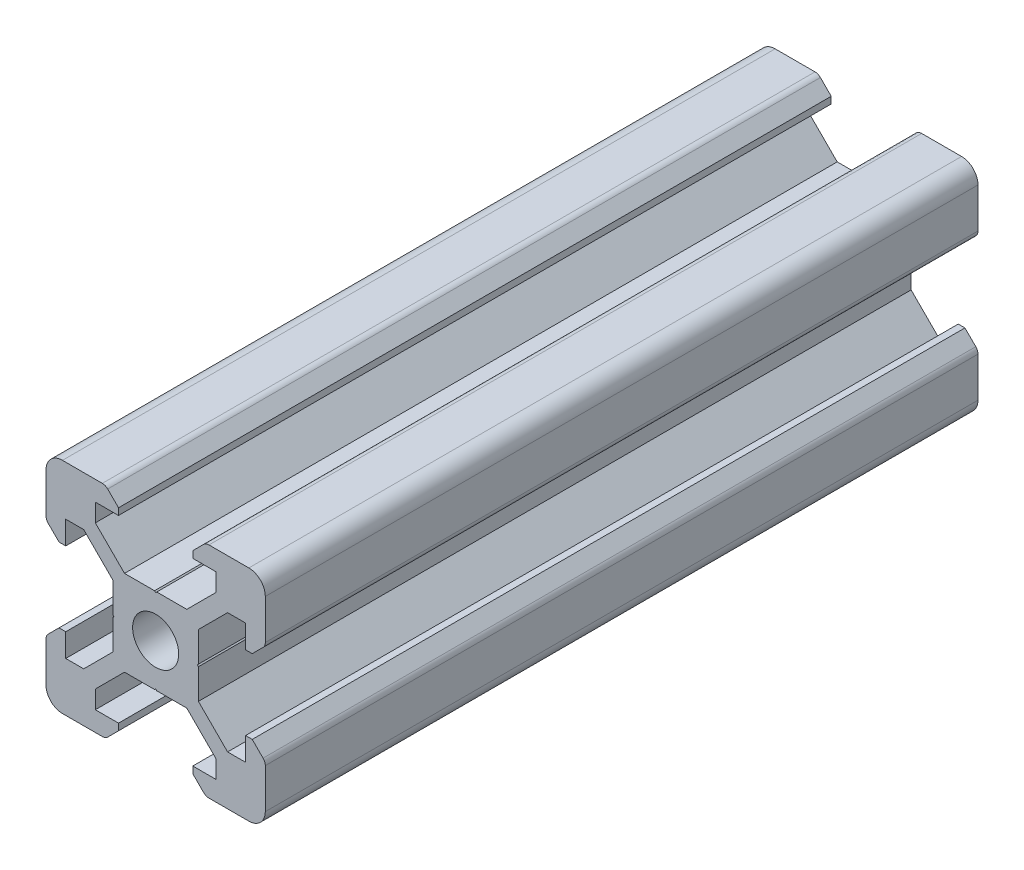
from build123d import *

# Parameters (mm, degrees)
SKETCH1_R           = 2.1
BOSS_EXTRUDE1_DEPTH = 65


with BuildPart() as part:
    # Sketch1 → Boss-Extrude1 (new body)
    with BuildSketch(Plane.XY):
        with BuildLine():
            Line((-8.5, 10), (-4.862792737, 10))
            ThreePointArc((-4.862792737, 10), (-4.598292737, 9.947387679), (-4.374060464, 9.797560464))
            Line((-4.374060464, 9.797560464), (-3.3865, 8.81))
            Line((-3.3865, 8.81), (-3.3865, 8.2))
            Line((-3.3865, 8.2), (-5.5, 8.2))
            Line((-5.5, 8.2), (-5.5, 6.561))
            Line((-5.5, 6.561), (-2.8395, 3.9005))
            Line((-2.8395, 3.9005), (-0.1, 3.9005))
            Line((-0.1, 3.9005), (0, 3.8005))
            Line((0, 3.8005), (0.1, 3.9005))
            Line((0.1, 3.9005), (2.8395, 3.9005))
            Line((2.8395, 3.9005), (5.5, 6.561))
            Line((5.5, 6.561), (5.5, 8.2))
            Line((5.5, 8.2), (3.3865, 8.2))
            Line((3.3865, 8.2), (3.3865, 8.81))
            Line((3.3865, 8.81), (4.374060464, 9.797560464))
            ThreePointArc((4.374060464, 9.797560464), (4.598292737, 9.947387679), (4.862792737, 10))
            Line((4.862792737, 10), (8.5, 10))
            ThreePointArc((8.5, 10), (9.560660172, 9.560660172), (10, 8.5))
            Line((10, 8.5), (10, 4.862792737))
            ThreePointArc((10, 4.862792737), (9.947387679, 4.598292737), (9.797560464, 4.374060464))
            Line((9.797560464, 4.374060464), (8.81, 3.3865))
            Line((8.81, 3.3865), (8.2, 3.3865))
            Line((8.2, 3.3865), (8.2, 5.5))
            Line((8.2, 5.5), (6.561, 5.5))
            Line((6.561, 5.5), (3.9005, 2.8395))
            Line((3.9005, 2.8395), (3.9005, 0.1))
            Line((3.9005, 0.1), (3.8005, 0))
            Line((3.8005, 0), (3.9005, -0.1))
            Line((3.9005, -0.1), (3.9005, -2.8395))
            Line((3.9005, -2.8395), (6.561, -5.5))
            Line((6.561, -5.5), (8.2, -5.5))
            Line((8.2, -5.5), (8.2, -3.3865))
            Line((8.2, -3.3865), (8.81, -3.3865))
            Line((8.81, -3.3865), (9.797560464, -4.374060464))
            ThreePointArc((9.797560464, -4.374060464), (9.947387679, -4.598292737), (10, -4.862792737))
            Line((10, -4.862792737), (10, -8.5))
            ThreePointArc((10, -8.5), (9.560660172, -9.560660172), (8.5, -10))
            Line((8.5, -10), (4.862792737, -10))
            ThreePointArc((4.862792737, -10), (4.598292737, -9.947387679), (4.374060464, -9.797560464))
            Line((4.374060464, -9.797560464), (3.3865, -8.81))
            Line((3.3865, -8.81), (3.3865, -8.2))
            Line((3.3865, -8.2), (5.5, -8.2))
            Line((5.5, -8.2), (5.5, -6.561))
            Line((5.5, -6.561), (2.8395, -3.9005))
            Line((2.8395, -3.9005), (0.1, -3.9005))
            Line((0.1, -3.9005), (0, -3.8005))
            Line((0, -3.8005), (-0.1, -3.9005))
            Line((-0.1, -3.9005), (-2.8395, -3.9005))
            Line((-2.8395, -3.9005), (-5.5, -6.561))
            Line((-5.5, -6.561), (-5.5, -8.2))
            Line((-5.5, -8.2), (-3.3865, -8.2))
            Line((-3.3865, -8.2), (-3.3865, -8.81))
            Line((-3.3865, -8.81), (-4.374060464, -9.797560464))
            ThreePointArc((-4.374060464, -9.797560464), (-4.598292737, -9.947387679), (-4.862792737, -10))
            Line((-4.862792737, -10), (-8.5, -10))
            ThreePointArc((-8.5, -10), (-9.560660172, -9.560660172), (-10, -8.5))
            Line((-10, -8.5), (-10, -4.862792737))
            ThreePointArc((-10, -4.862792737), (-9.947387679, -4.598292737), (-9.797560464, -4.374060464))
            Line((-9.797560464, -4.374060464), (-8.81, -3.3865))
            Line((-8.81, -3.3865), (-8.2, -3.3865))
            Line((-8.2, -3.3865), (-8.2, -5.5))
            Line((-8.2, -5.5), (-6.561, -5.5))
            Line((-6.561, -5.5), (-3.9005, -2.8395))
            Line((-3.9005, -2.8395), (-3.9005, -0.1))
            Line((-3.9005, -0.1), (-3.8005, 0))
            Line((-3.8005, 0), (-3.9005, 0.1))
            Line((-3.9005, 0.1), (-3.9005, 2.8395))
            Line((-3.9005, 2.8395), (-6.561, 5.5))
            Line((-6.561, 5.5), (-8.2, 5.5))
            Line((-8.2, 5.5), (-8.2, 3.3865))
            Line((-8.2, 3.3865), (-8.81, 3.3865))
            Line((-8.81, 3.3865), (-9.797560464, 4.374060464))
            ThreePointArc((-9.797560464, 4.374060464), (-9.947387679, 4.598292737), (-10, 4.862792737))
            Line((-10, 4.862792737), (-10, 8.5))
            ThreePointArc((-10, 8.5), (-9.560660172, 9.560660172), (-8.5, 10))
        make_face()
        Circle(SKETCH1_R, mode=Mode.SUBTRACT)
    extrude(amount=BOSS_EXTRUDE1_DEPTH)


solid = part.part
